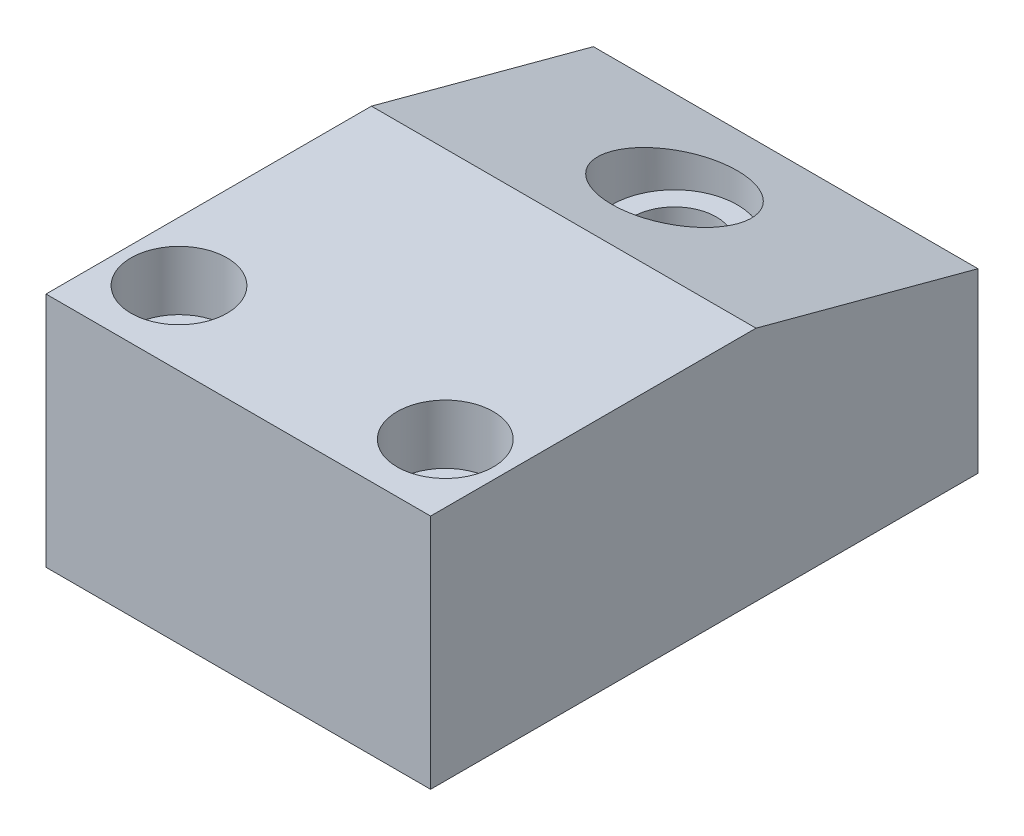
from build123d import *

# Parameters (mm, degrees)
EXTRUDE1_DEPTH      = 20.6375
EXTRUDE1_DEPTH_BACK = 20.6375
CUT_EXTRUDE1_REACH  = 27.4
SKETCH4_R           = 7.99973
SKETCH4_R_2         = 4.3688
EXTRUDE2_DEPTH      = 9.144
EXTRUDE3_DEPTH      = 7.9375
EXTRUDE3_DEPTH_BACK = 7.9375
CUT_EXTRUDE2_DEPTH  = 24.765
LPATTERN2_COUNT     = 3
LPATTERN2_PITCH     = 1.5875
FILLET1_R           = 0.7874
SKETCH8_R           = 1.5875
HOLE1_AT_2_COUNT    = 2
HOLE1_AT_2_PITCH    = 28.575


with BuildPart() as part:
    # Sketch1 → Extrude1 (new body, two sides)
    with BuildSketch(Plane(origin=(0, 0, 0), x_dir=(0, 0, -1), z_dir=(1, 0, 0))) as extrude1_sk:
        Polygon((34.925, 25.4), (58.748015024, 19.016642363), (58.748015024, 12.442638617), (61.1124, 11.809103573), (61.1124, 0), (0, 0), (0, 25.4), align=None)
    extrude(amount=EXTRUDE1_DEPTH)
    extrude(extrude1_sk.sketch, amount=-EXTRUDE1_DEPTH_BACK)

    # Cut-Extrude1: up to this plane
    cut_extrude1_end = Plane(origin=(-20.6375, 12.442638617, -58.748015024), z_dir=(0, 0.965925826, -0.258819045))
    # Sketch2 → Cut-Extrude1 (cut, up to the surface)
    with BuildSketch(Plane.XZ, mode=Mode.PRIVATE) as cut_extrude1_sk1:
        with BuildLine():
            Line((20.6375, -61.1124), (12.7, -61.1124))
            ThreePointArc((12.7, -61.1124), (13.832391453, -59.407629596), (15.769776585, -58.748015024))
            Line((15.769776585, -58.748015024), (20.6375, -58.748015024))
            Line((20.6375, -58.748015024), (20.6375, -61.1124))
        make_face()
    cut_extrude1_tool1 = split(extrude(cut_extrude1_sk1.sketch, amount=-CUT_EXTRUDE1_REACH, mode=Mode.PRIVATE), bisect_by=cut_extrude1_end, keep=Keep.BOTH, mode=Mode.PRIVATE)
    add(cut_extrude1_tool1.solids().sort_by_distance((17.033922, 0, -59.993139))[0], mode=Mode.SUBTRACT)
    # Sketch2 → Cut-Extrude1 (cut, up to the surface)
    with BuildSketch(Plane.XZ, mode=Mode.PRIVATE) as cut_extrude1_sk2:
        with BuildLine():
            Line((-20.6375, -58.748015024), (-15.769776585, -58.748015024))
            ThreePointArc((-15.769776585, -58.748015024), (-13.832391453, -59.407629596), (-12.7, -61.1124))
            Line((-12.7, -61.1124), (-20.6375, -61.1124))
            Line((-20.6375, -61.1124), (-20.6375, -58.748015024))
        make_face()
    cut_extrude1_tool2 = split(extrude(cut_extrude1_sk2.sketch, amount=-CUT_EXTRUDE1_REACH, mode=Mode.PRIVATE), bisect_by=cut_extrude1_end, keep=Keep.BOTH, mode=Mode.PRIVATE)
    add(cut_extrude1_tool2.solids().sort_by_distance((-17.033922, 0, -59.993139))[0], mode=Mode.SUBTRACT)

    # Sketch3 → Cut-Revolve1 (revolve, cut)
    with BuildSketch(Plane(origin=(0, 0, 0), x_dir=(0, 0, -1), z_dir=(1, 0, 0)), mode=Mode.PRIVATE) as cut_revolve1_sk:
        Polygon((40.0687, 24.021749739), (40.0687, 17.232918981), (42.3162, 17.232918981), (42.3162, 3.175), (38.81247, 3.175), (38.81247, 0), (46.8122, 0), (46.8122, 24.021749739), align=None)
    revolve(cut_revolve1_sk.sketch.rotate(Axis((0, -4.910727806, -46.8122), (0, 1, 0)), 180), axis=Axis((0, -4.910727806, -46.8122), (0, 1, 0)), mode=Mode.SUBTRACT)  # turned: the seam where the file's is

    # Sketch4 → Extrude2 (add)
    with BuildSketch(Plane.XZ.offset(-3.175)):
        with Locations(Location((0, -46.8122, 0), (0, 0, 270))):  # turned: the seam where the file's is
            Circle(SKETCH4_R)
        with Locations(Location((0, -46.8122, 0), (0, 0, 270))):  # turned: the seam where the file's is
            Circle(SKETCH4_R_2, mode=Mode.SUBTRACT)
    extrude(amount=EXTRUDE2_DEPTH)

    # S2D0005 → Cut-Revolve2 (revolve, cut)
    with BuildSketch(Plane(origin=(0, 0, -7.9248), x_dir=(-1, 0, 0), z_dir=(0, 0, 1)), mode=Mode.PRIVATE) as cut_revolve2_sk:
        Polygon((0, 0), (6.4635, 0), (6.4635, -2.642), (1.5875, -2.642), (1.5875, -6.35), (0, -6.35), align=None)
    revolve(cut_revolve2_sk.sketch.rotate(Axis((0, 10.867513557, -7.9248), (0, -1, 0)), 270), axis=Axis((0, 10.867513557, -7.9248), (0, -1, 0)), mode=Mode.SUBTRACT)  # turned: the seam where the file's is

    # Sketch6 → Extrude3 (add, two sides)
    with BuildSketch(Plane(origin=(0, 0, 0), x_dir=(0, 0, -1), z_dir=(1, 0, 0))) as extrude3_sk:
        Polygon((61.1124, 2.789570434), (65.8876, 1.51005945), (65.8876, 8.136655225), (61.1124, 9.416166209), align=None)
    extrude(amount=EXTRUDE3_DEPTH)
    extrude(extrude3_sk.sketch, amount=-EXTRUDE3_DEPTH_BACK)

    # Sketch7 → Cut-Extrude2 (cut, symmetric)
    with BuildSketch(Plane(origin=(0, 0, 0), x_dir=(0, 0, -1), z_dir=(1, 0, 0))):
        Polygon((65.8876, 3.49443445), (65.8876, 2.70068445), (65.09385, 2.913369121), (65.09385, 3.281749778), align=None)
    cut_extrude2 = extrude(amount=CUT_EXTRUDE2_DEPTH, both=True, mode=Mode.SUBTRACT)

    # LPattern2: Cut-Extrude2 ×3
    with Locations(*[(0, i * LPATTERN2_PITCH, 0) for i in range(1, LPATTERN2_COUNT)]):
        add(cut_extrude2, mode=Mode.SUBTRACT)

    # Fillet1
    fillet1_edges = [part.edges().sort_by_distance(p)[0] for p in [
        (0, 8.136655225, -65.8876),
        (0, 1.51005945, -65.8876),
    ]]
    fillet(fillet1_edges, radius=FILLET1_R)

    # Sketch9 → Hole1 (revolve, cut)
    with BuildSketch(Plane(origin=(-14.2875, 25.4, -7.9248), x_dir=(0, 0, 1), z_dir=(1, 0, 0))):
        Polygon((0, 0), (0, 31.369), (3.5685, 31.369), (3.5685, 6.35), (5.1562, 6.35), (5.1562, 0), align=None)
    hole1 = revolve(axis=Axis((-14.2875, -84.6, -7.9248), (0, 1, 0)), mode=Mode.SUBTRACT)

    # Hole1 at 2: Hole1 ×2
    with Locations(*[(i * HOLE1_AT_2_PITCH, 0, 0) for i in range(1, HOLE1_AT_2_COUNT)]):
        add(hole1, mode=Mode.SUBTRACT)


with BuildPart() as body_2:
    # Sketch8 → Revolve1 (revolve)
    with BuildSketch(Plane(origin=(0, 0, 0), x_dir=(0, 0, -1), z_dir=(1, 0, 0)), mode=Mode.PRIVATE) as revolve1_sk:
        with Locations((12.8008, 1.0545)):
            Circle(SKETCH8_R)
    revolve(revolve1_sk.sketch.rotate(Axis((0, -0.66675, -7.9248), (0, 1, 0)), 180), axis=Axis((0, -0.66675, -7.9248), (0, 1, 0)))  # turned: the seam where the file's is


solid = Compound([part.part, body_2.part])
